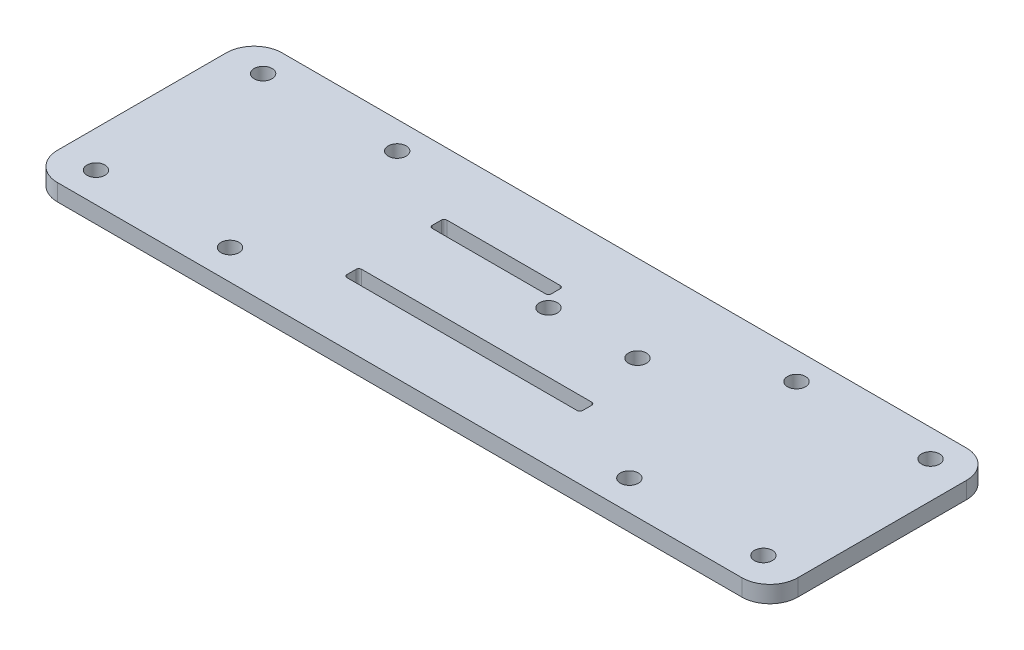
from build123d import *

# Parameters (mm, degrees)
SKETCH_1_W      = 132
SKETCH_1_H      = 40.05
SKETCH_1_R      = 1.6
SKETCH_1_W_2    = 21.2
SKETCH_1_H_2    = 2.6
SKETCH_1_W_3    = 42
EXTRUDE_1_DEPTH = 3
FILLET_1_R      = 5
FILLET_2_R      = 5
FILLET_3_R      = 0.5


with BuildPart() as part:
    # 草图1 → 凸台-拉伸1 (new body)
    with BuildSketch(Plane(origin=(0, 0, 0), x_dir=(1, 0, 0), z_dir=(0, 1, 0))):
        with Locations((-40.850806452, 4.522983871)):
            Rectangle(SKETCH_1_W, SKETCH_1_H)
        with Locations((18.649193548, 19.647983871)):
            Circle(SKETCH_1_R, mode=Mode.SUBTRACT)
        with Locations((18.649193548, -10.152016129)):
            Circle(SKETCH_1_R, mode=Mode.SUBTRACT)
        with Locations((-5.250806452, 19.647983871)):
            Circle(SKETCH_1_R, mode=Mode.SUBTRACT)
        with Locations((-5.250806452, -10.152016129)):
            Circle(SKETCH_1_R, mode=Mode.SUBTRACT)
        with Locations((-100.350806452, -10.152016129)):
            Circle(SKETCH_1_R, mode=Mode.SUBTRACT)
        with Locations((-76.450806452, -10.152016129)):
            Circle(SKETCH_1_R, mode=Mode.SUBTRACT)
        with Locations((-100.350806452, 19.647983871)):
            Circle(SKETCH_1_R, mode=Mode.SUBTRACT)
        with Locations((-76.450806452, 19.647983871)):
            Circle(SKETCH_1_R, mode=Mode.SUBTRACT)
        with Locations((-38.749865004, 8.922983871)):
            Circle(SKETCH_1_R, mode=Mode.SUBTRACT)
        with Locations((-23.050806452, 9.094915776)):
            Circle(SKETCH_1_R, mode=Mode.SUBTRACT)
        with Locations((-51.250806452, 12.122983871)):
            Rectangle(SKETCH_1_W_2, SKETCH_1_H_2, mode=Mode.SUBTRACT)
        with Locations((-40.850806452, -3.077016129)):
            Rectangle(SKETCH_1_W_3, SKETCH_1_H_2, mode=Mode.SUBTRACT)
    extrude(amount=EXTRUDE_1_DEPTH)

    # 圆角1
    fillet_1_edges = [part.edges().sort_by_distance(p)[0] for p in [
        (25.149193548, 1.5, -24.547983871),
    ]]
    fillet(fillet_1_edges, radius=FILLET_1_R)

    # 圆角2
    fillet_2_edges = [part.edges().sort_by_distance(p)[0] for p in [
        (25.149193548, 1.5, 15.502016129),
        (-106.850806452, 1.5, 15.502016129),
        (-106.850806452, 1.5, -24.547983871),
    ]]
    fillet(fillet_2_edges, radius=FILLET_2_R)

    # 圆角3
    fillet_3_edges = [part.edges().sort_by_distance(p)[0] for p in [
        (-40.650806452, 1.5, -10.822983871),
        (-40.650806452, 1.5, -13.422983871),
        (-61.850806452, 1.5, -13.422983871),
        (-61.850806452, 1.5, -10.822983871),
        (-19.850806452, 1.5, 4.377016129),
        (-19.850806452, 1.5, 1.777016129),
        (-61.850806452, 1.5, 1.777016129),
        (-61.850806452, 1.5, 4.377016129),
    ]]
    fillet(fillet_3_edges, radius=FILLET_3_R)


solid = part.part
